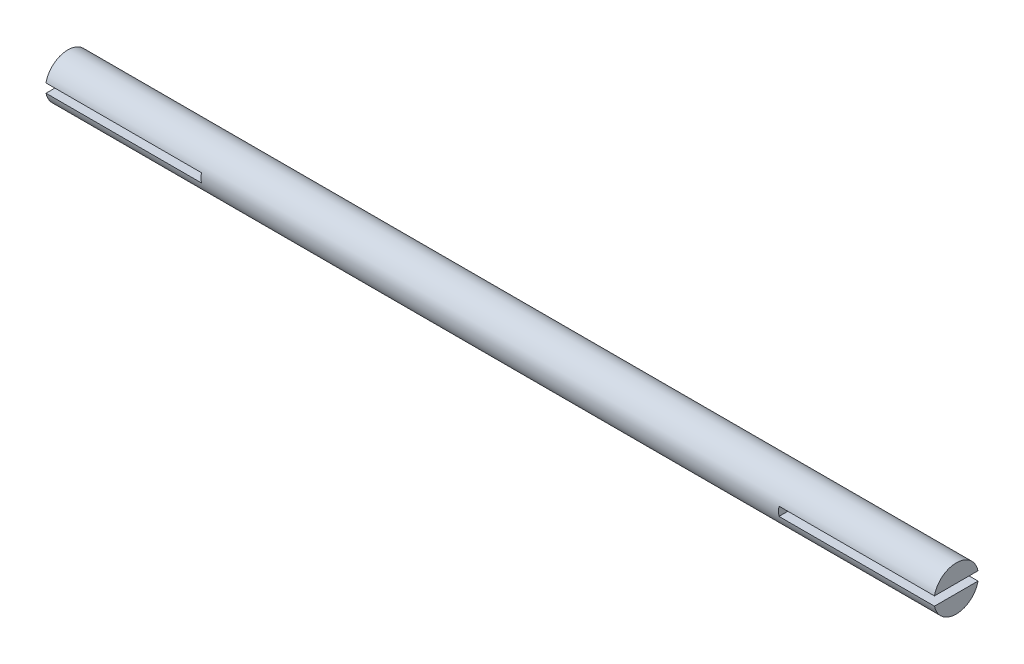
from build123d import *

# Parameters (mm, degrees)
SKETCH_1_R          = 5
EXTRUDE_1_DEPTH     = 100
CUT_EXTRUDE_1_DEPTH = 35


with BuildPart() as part:
    # 草图1 → 凸台-拉伸1 (new body)
    with BuildSketch(Plane(origin=(0, 0, 0), x_dir=(0, 0, -1), z_dir=(1, 0, 0))):
        Circle(SKETCH_1_R)
    extrude(amount=EXTRUDE_1_DEPTH)

    # 草图2 → 切除-拉伸1 (cut)
    with BuildSketch(Plane(origin=(100, 0, 0), x_dir=(0, 0, -1), z_dir=(1, 0, 0))):
        Polygon((0, 1), (7.225106676, 1), (7.225106676, -1), (-6.455679515, -1), (-6.455679515, 1), align=None)
    extrude(amount=-CUT_EXTRUDE_1_DEPTH, mode=Mode.SUBTRACT)

    # 镜向1: part across plane


with BuildPart() as part_1:
    add(part.part)
    add(part.part.mirror(Plane(origin=(0, 0, 0), x_dir=(0, 0, 1), z_dir=(1, 0, 0))))


solid = part_1.part
